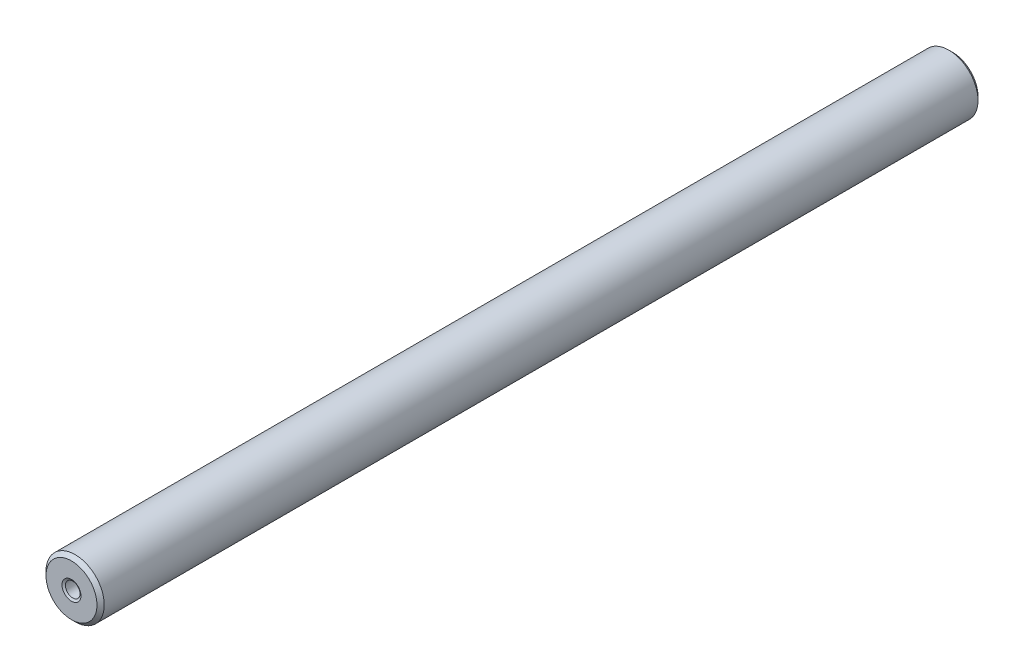
from build123d import *

# Parameters (mm, degrees)
CHAMFER1_SIZE         = 0.5
CHAMFER2_SIZE         = 0.3
CHAMFER2_SIZE2        = 0.173205081
CHAMFER2_PART_2_SIZE  = 0.3
CHAMFER2_PART_2_SIZE2 = 0.173205081
CHAMFER2_PART_3_SIZE  = 0.3
CHAMFER2_PART_3_SIZE2 = 0.173205081
CHAMFER2_PART_4_SIZE  = 0.3
CHAMFER2_PART_4_SIZE2 = 0.173205081


with BuildPart() as part:
    # Sketch1 → Revolve1 (revolve)
    with BuildSketch(Plane(origin=(0, 0, 0), x_dir=(1, 0, 0), z_dir=(0, 1, 0))):
        Polygon((-1, 0), (-4, 0), (-4, -121), (-1, -121), (-1, -119), (0, -119), (0, -2), (-1, -2), align=None)
    revolve(axis=Axis((0, 0, 119), (0, 0, -1)))

    # Chamfer1
    chamfer1_edges = [part.edges().sort_by_distance(p)[0] for p in [
        (4, 0, 121),
        (4, 0, 0),
    ]]
    chamfer(chamfer1_edges, length=CHAMFER1_SIZE)

    # Chamfer2
    chamfer2_edges = [part.edges().sort_by_distance(p)[0] for p in [
        (1, 0, 2),
    ]]
    chamfer2_side = [part.faces().sort_by_distance(p)[0] for p in [
        (0, 0, 2),
    ]]
    chamfer(chamfer2_edges, length=CHAMFER2_SIZE, length2=CHAMFER2_SIZE2, reference=chamfer2_side[0])

    # Chamfer2 part 2
    chamfer2_part_2_edges = [part.edges().sort_by_distance(p)[0] for p in [
        (1, 0, 119),
    ]]
    chamfer2_part_2_side = [part.faces().sort_by_distance(p)[0] for p in [
        (1, 0, 120),
    ]]
    chamfer(chamfer2_part_2_edges, length=CHAMFER2_PART_2_SIZE, length2=CHAMFER2_PART_2_SIZE2, reference=chamfer2_part_2_side[0])

    # Chamfer2 part 3
    chamfer2_part_3_edges = [part.edges().sort_by_distance(p)[0] for p in [
        (1, 0, 121),
    ]]
    chamfer2_part_3_side = [part.faces().sort_by_distance(p)[0] for p in [
        (3.401005051, 0, 121),
    ]]
    chamfer(chamfer2_part_3_edges, length=CHAMFER2_PART_3_SIZE, length2=CHAMFER2_PART_3_SIZE2, reference=chamfer2_part_3_side[0])

    # Chamfer2 part 4
    chamfer2_part_4_edges = [part.edges().sort_by_distance(p)[0] for p in [
        (1, 0, 0),
    ]]
    chamfer2_part_4_side = [part.faces().sort_by_distance(p)[0] for p in [
        (1, 0, 1),
    ]]
    chamfer(chamfer2_part_4_edges, length=CHAMFER2_PART_4_SIZE, length2=CHAMFER2_PART_4_SIZE2, reference=chamfer2_part_4_side[0])


solid = part.part
